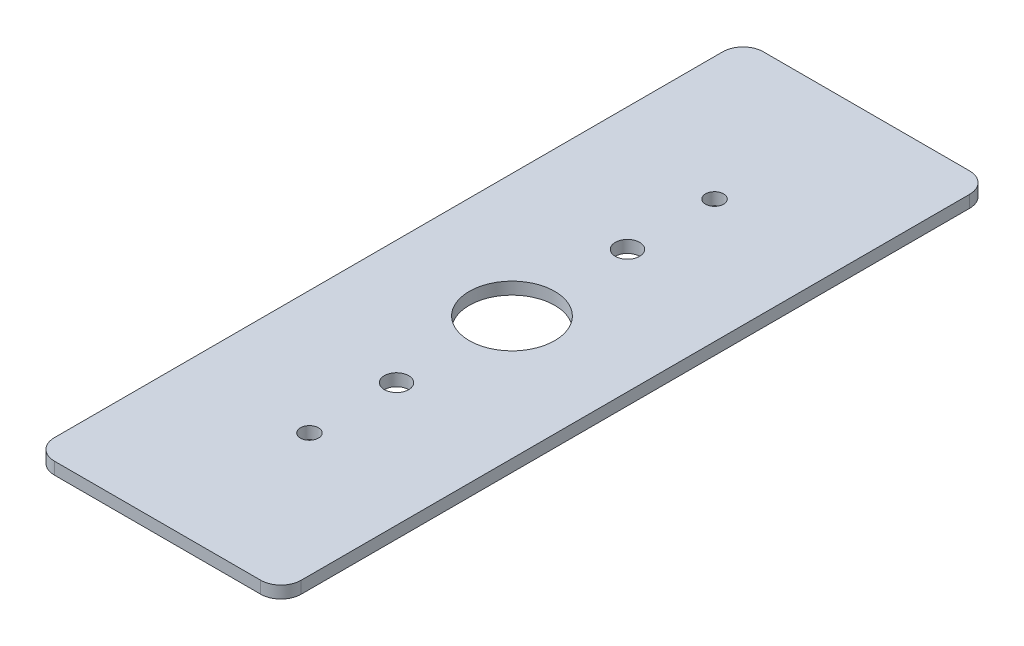
from build123d import *

# Parameters (mm, degrees)
SKETCH1_W               = 30.95625
SKETCH1_H               = 88.9
BOSS_EXTRUDE1_DEPTH     = 1.524
FILLET1_R               = 2.54
SKETCH6_R               = 1.524
CUT_EXTRUDE1_DEPTH      = 2.524
F_4_40_TAPPED_HOLE1_D   = 2.2606
F_1_2_13_TAPPED_HOLE1_D = 10.71626


with BuildPart() as part:
    # Sketch1 → Boss-Extrude1 (new body)
    with BuildSketch(Plane(origin=(0, 0, 0), x_dir=(1, 0, 0), z_dir=(0, 1, 0))):
        Rectangle(SKETCH1_W, SKETCH1_H)
    extrude(amount=BOSS_EXTRUDE1_DEPTH)

    # Fillet1
    fillet1_edges = [part.edges().sort_by_distance(p)[0] for p in [
        (15.478125, 0.762, -44.45),
        (15.478125, 0.762, 44.45),
        (-15.478125, 0.762, 44.45),
        (-15.478125, 0.762, -44.45),
    ]]
    fillet(fillet1_edges, radius=FILLET1_R)

    # Sketch6 → Cut-Extrude1 (cut, through all)
    with BuildSketch(Plane.XZ):
        with Locations((0, 14.478)):
            Circle(SKETCH6_R)
        with Locations((0, -14.478)):
            Circle(SKETCH6_R)
    extrude(amount=-CUT_EXTRUDE1_DEPTH, mode=Mode.SUBTRACT)

    # #4-40 Tapped Hole1 (through all)
    with Locations(Plane(origin=(0, 1.524, 0), x_dir=(-1, 0, 0), z_dir=(0, 1, 0))):
        with Locations((0, 25.4), (0, -25.4)):
            Hole(F_4_40_TAPPED_HOLE1_D / 2)

    # 1/2-13 Tapped Hole1 (through all)
    with Locations(Plane(origin=(0, 1.524, 0), x_dir=(-1, 0, 0), z_dir=(0, 1, 0))):
        with Locations((0, 0)):
            Hole(F_1_2_13_TAPPED_HOLE1_D / 2)


solid = part.part
